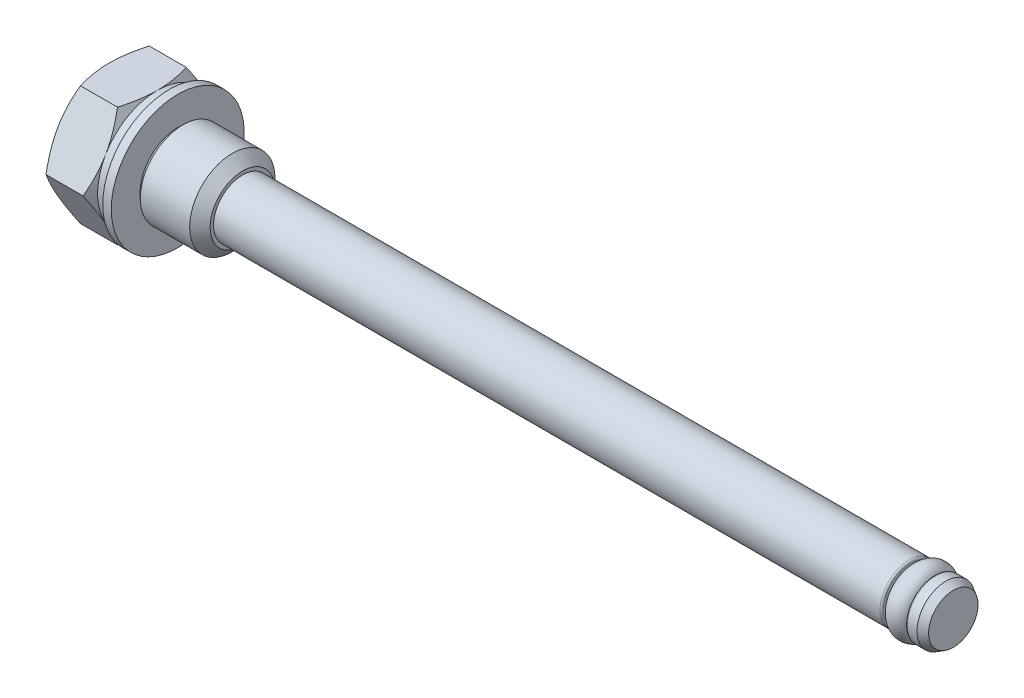
from build123d import *

# Parameters (mm, degrees)
SKETCH2_W          = 20
SKETCH2_H          = 20
CUT_EXTRUDE1_DEPTH = 5
SKETCH4_W          = 0.5
SKETCH4_H          = 1.75


with BuildPart() as part:
    # Sketch1 → Revolve1 (revolve)
    with BuildSketch(Plane.XY):
        with BuildLine():
            Line((-3.5, 0), (-3.5, 3.5))
            Line((-3.5, 3.5), (-2.1, 5.924871131))
            Line((-2.1, 5.924871131), (-0.7, 3.5))
            Line((-0.7, 3.5), (0, 3.5))
            Line((0, 3.5), (0, 2.5))
            Line((0, 2.5), (0.258578644, 2.241421356))
            ThreePointArc((0.258578644, 2.241421356), (0.4, 2.182842712), (0.541421356, 2.241421356))
            Line((0.541421356, 2.241421356), (0.8, 2.5))
            Line((0.8, 2.5), (3.7, 2.5))
            Line((3.7, 2.5), (4.3, 1.9))
            Line((4.3, 1.9), (4.3, 1.7))
            Line((4.3, 1.7), (43.4, 1.7))
            ThreePointArc((43.4, 1.7), (43.470710678, 1.670710678), (43.5, 1.6))
            Line((43.5, 1.6), (43.5, 1.3))
            ThreePointArc((43.5, 1.3), (43.529289322, 1.229289322), (43.6, 1.2))
            Line((43.6, 1.2), (44.8, 1.2))
            ThreePointArc((44.8, 1.2), (44.870710678, 1.229289322), (44.9, 1.3))
            Line((44.9, 1.3), (44.9, 1.6))
            ThreePointArc((44.9, 1.6), (44.929289322, 1.670710678), (45, 1.7))
            Line((45, 1.7), (45.566987298, 1.7))
            Line((45.566987298, 1.7), (46, 1.45))
            Line((46, 1.45), (46, 0))
            Line((46, 0), (-3.5, 0))
        make_face()
    revolve(axis=Axis((46, 0, 0), (-1, 0, 0)))

    # Sketch2 → Cut-Extrude1 (cut)
    with BuildSketch(Plane.ZY.offset(3.5)):
        Rectangle(SKETCH2_W, SKETCH2_H)
        Polygon((2.020725942, -3.5), (4.041451884, 0), (2.020725942, 3.5), (-2.020725942, 3.5), (-4.041451884, 0), (-2.020725942, -3.5), align=None, mode=Mode.SUBTRACT)
    extrude(amount=-CUT_EXTRUDE1_DEPTH, mode=Mode.SUBTRACT)

    # Sketch3 → Revolve2 (revolve)
    with BuildSketch(Plane.XY):
        with BuildLine():
            Line((43.5, 1.2), (44.9, 1.2))
            ThreePointArc((44.9, 1.2), (44.2, 1.9), (43.5, 1.2))
        make_face()
    revolve(axis=Axis((44.9, 0, 0), (-1, 0, 0)))

    # Sketch4 → Revolve3 (revolve)
    with BuildSketch(Plane.XY):
        with Locations((0.25, 3.025)):
            Rectangle(SKETCH4_W, SKETCH4_H)
    revolve(axis=Axis((0.5, 0, 0), (-1, 0, 0)))


solid = part.part
